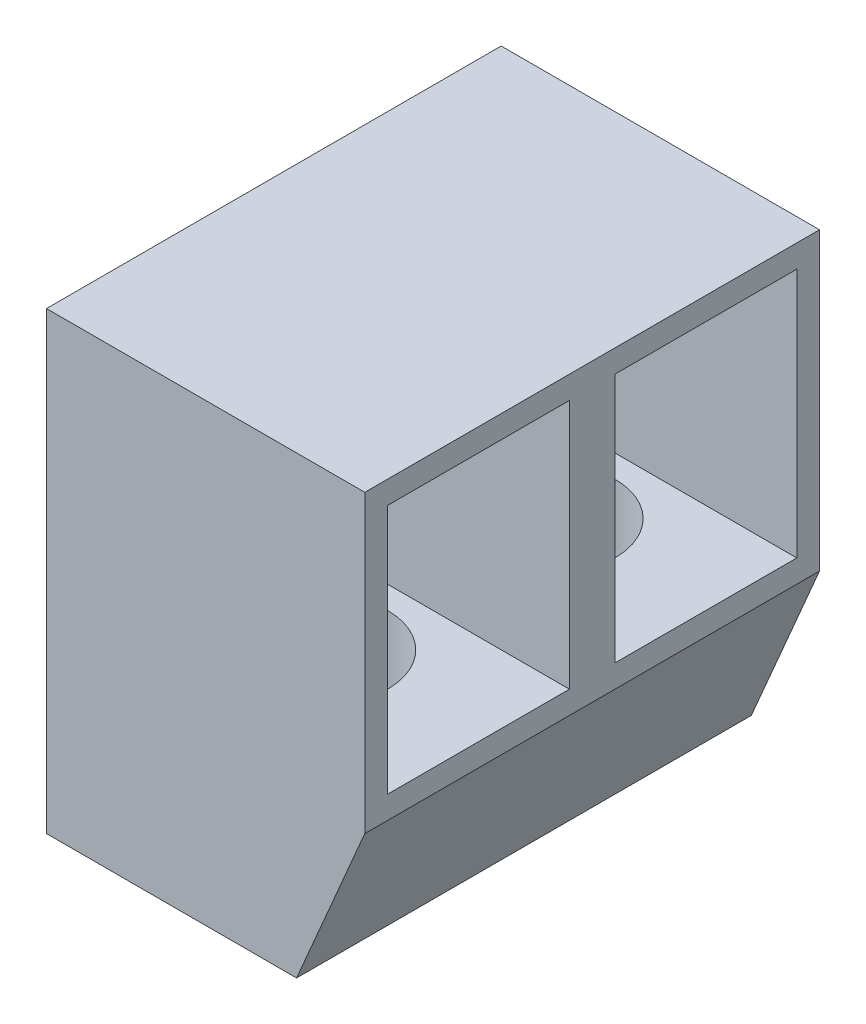
from build123d import *

# Parameters (mm, degrees)
BOSS_EXTRUDE1_DEPTH = 10
CUT_EXTRUDE1_REACH  = 9
SKETCH2_W           = 4
SKETCH2_H           = 5.5
CUT_EXTRUDE2_REACH  = 6
SKETCH3_R           = 1.5


with BuildPart() as part:
    # Sketch1 → Boss-Extrude1 (new body)
    with BuildSketch(Plane.XY):
        Polygon((0, 0), (0, 10), (7, 10), (7, 3.5), (5.5, 0), align=None)
    extrude(amount=BOSS_EXTRUDE1_DEPTH)

    # Sketch2 → Cut-Extrude1 (cut, up to next)
    with BuildSketch(Plane(origin=(7, 0, 0), x_dir=(0, 0, -1), z_dir=(1, 0, 0)), mode=Mode.PRIVATE) as cut_extrude1_sk1:
        with Locations((-7.5, 6.75)):
            Rectangle(SKETCH2_W, SKETCH2_H)
    cut_extrude1_tool1 = extrude(cut_extrude1_sk1.sketch, amount=-CUT_EXTRUDE1_REACH, mode=Mode.PRIVATE) & part.part
    add(cut_extrude1_tool1.solids().sort_by_distance((7, 6.75, 7.5))[0], mode=Mode.SUBTRACT)
    # Sketch2 → Cut-Extrude1 (cut, up to next)
    with BuildSketch(Plane(origin=(7, 0, 0), x_dir=(0, 0, -1), z_dir=(1, 0, 0)), mode=Mode.PRIVATE) as cut_extrude1_sk2:
        with Locations((-2.5, 6.75)):
            Rectangle(SKETCH2_W, SKETCH2_H)
    cut_extrude1_tool2 = extrude(cut_extrude1_sk2.sketch, amount=-CUT_EXTRUDE1_REACH, mode=Mode.PRIVATE) & part.part
    add(cut_extrude1_tool2.solids().sort_by_distance((7, 6.75, 2.5))[0], mode=Mode.SUBTRACT)

    # Sketch3 → Cut-Extrude2 (cut, up to next)
    with BuildSketch(Plane(origin=(0, 4, 0), x_dir=(1, 0, 0), z_dir=(0, 1, 0)), mode=Mode.PRIVATE) as cut_extrude2_sk1:
        with Locations((3.5, -2.5)):
            Circle(SKETCH3_R)
    cut_extrude2_tool1 = extrude(cut_extrude2_sk1.sketch, amount=-CUT_EXTRUDE2_REACH, mode=Mode.PRIVATE) & part.part
    add(cut_extrude2_tool1.solids().sort_by_distance((3.5, 4, 2.5))[0], mode=Mode.SUBTRACT)
    # Sketch3 → Cut-Extrude2 (cut, up to next)
    with BuildSketch(Plane(origin=(0, 4, 0), x_dir=(1, 0, 0), z_dir=(0, 1, 0)), mode=Mode.PRIVATE) as cut_extrude2_sk2:
        with Locations((3.5, -7.5)):
            Circle(SKETCH3_R)
    cut_extrude2_tool2 = extrude(cut_extrude2_sk2.sketch, amount=-CUT_EXTRUDE2_REACH, mode=Mode.PRIVATE) & part.part
    add(cut_extrude2_tool2.solids().sort_by_distance((3.5, 4, 7.5))[0], mode=Mode.SUBTRACT)


solid = part.part
